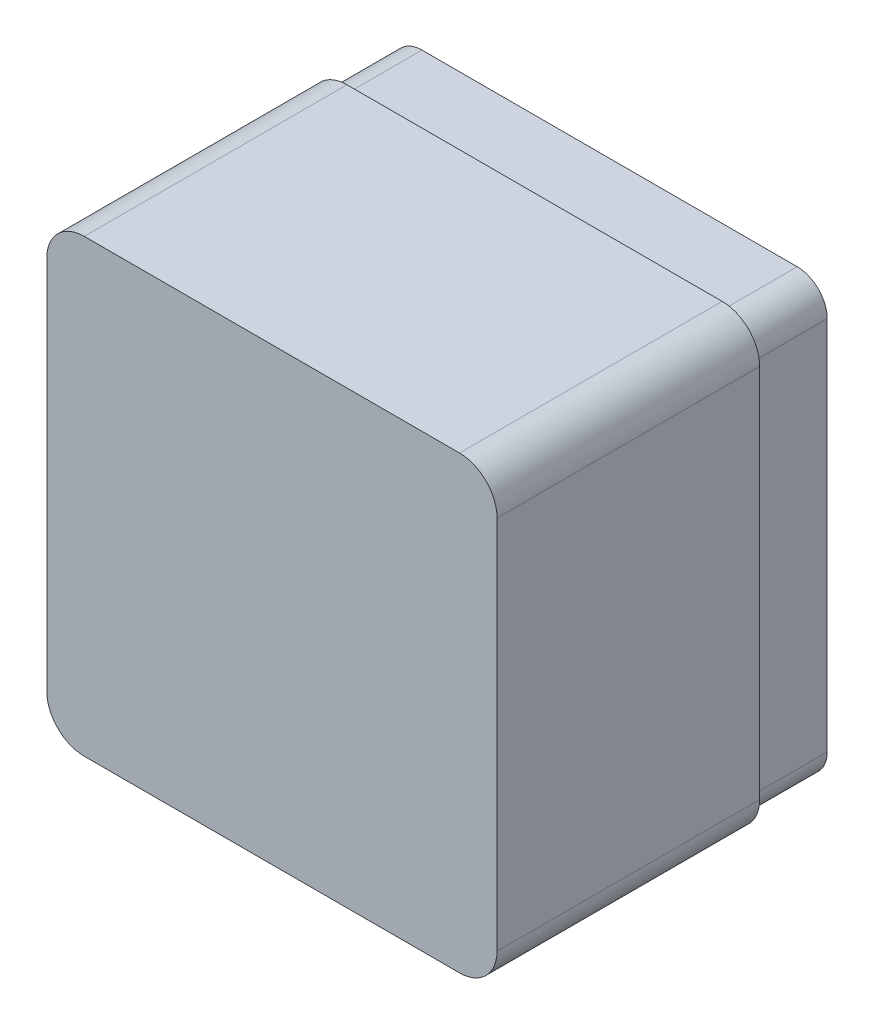
from build123d import *

# Parameters (mm, degrees)
SKETCH1_W           = 120
SKETCH1_H           = 120
BOSS_EXTRUDE1_DEPTH = 90
FILLET1_R           = 10
SHELL1_T            = -4
CUT_EXTRUDE1_DEPTH  = 20


with BuildPart() as part:
    # Sketch1 → Boss-Extrude1 (new body)
    with BuildSketch(Plane.XY):
        with Locations((60, -60)):
            Rectangle(SKETCH1_W, SKETCH1_H)
    extrude(amount=BOSS_EXTRUDE1_DEPTH)

    # Fillet1
    fillet1_edges = [part.edges().sort_by_distance(p)[0] for p in [
        (0, 0, 45),
        (120, 0, 45),
        (120, -120, 45),
        (0, -120, 45),
    ]]
    fillet(fillet1_edges, radius=FILLET1_R)

    # Shell1
    shell1_openings = [part.faces().sort_by_distance(p)[0] for p in [
        (60, -60, 0),
    ]]
    offset(amount=SHELL1_T, openings=shell1_openings, kind=Kind.INTERSECTION)

    # Sketch2 → Cut-Extrude1 (cut)
    with BuildSketch(Plane(origin=(0, 0, 0), x_dir=(-1, 0, 0), z_dir=(0, 0, -1))):
        with BuildLine():
            Line((-120, -10), (-120, -110))
            ThreePointArc((-120, -110), (-117.071067812, -117.071067812), (-110, -120))
            Line((-110, -120), (-10, -120))
            ThreePointArc((-10, -120), (-2.928932188, -117.071067812), (0, -110))
            Line((0, -110), (0, -10))
            ThreePointArc((0, -10), (-2.928932188, -2.928932188), (-10, 0))
            Line((-10, 0), (-110, 0))
            ThreePointArc((-110, 0), (-117.071067812, -2.928932188), (-120, -10))
        make_face()
        with BuildLine():
            Line((-118, -10), (-118, -110))
            ThreePointArc((-118, -110), (-115.656854249, -115.656854249), (-110, -118))
            Line((-110, -118), (-10, -118))
            ThreePointArc((-10, -118), (-4.343145751, -115.656854249), (-2, -110))
            Line((-2, -110), (-2, -10))
            ThreePointArc((-2, -10), (-4.343145751, -4.343145751), (-10, -2))
            Line((-10, -2), (-110, -2))
            ThreePointArc((-110, -2), (-115.656854249, -4.343145751), (-118, -10))
        make_face(mode=Mode.SUBTRACT)
    extrude(amount=-CUT_EXTRUDE1_DEPTH, mode=Mode.SUBTRACT)


solid = part.part
